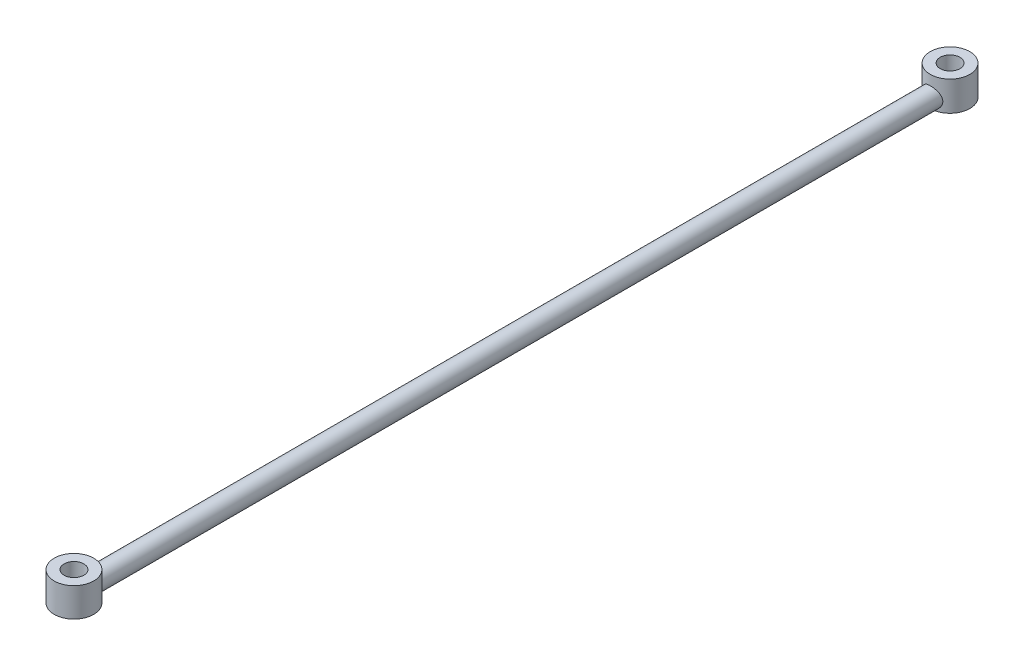
from build123d import *

# Parameters (mm, degrees)
SKETCH_1_R        = 3
SKETCH_1_R_2      = 1.5
EXTRUDE_1_DEPTH   = 3
EXTRUDE_1_2_DEPTH = 3
SKETCH_2_R        = 1.5
EXTRUDE_2_DEPTH   = 129.8
SKETCH_3_R        = 3
SKETCH_3_R_2      = 1.5
EXTRUDE_3_DEPTH   = 1.5
SKETCH_4_R        = 3
SKETCH_4_R_2      = 1.5
EXTRUDE_4_DEPTH   = 1.4


with BuildPart() as part:
    # 草图1 → 凸台-拉伸1 (new body)
    with BuildSketch(Plane(origin=(0, 0, 0), x_dir=(1, 0, 0), z_dir=(0, 1, 0))):
        Circle(SKETCH_1_R)
        Circle(SKETCH_1_R_2, mode=Mode.SUBTRACT)
    extrude(amount=EXTRUDE_1_DEPTH)



with BuildPart() as body_2:
    # 草图1 → Extrude 1 2 (new body)
    with BuildSketch(Plane(origin=(0, 0, 0), x_dir=(1, 0, 0), z_dir=(0, 1, 0))):
        with Locations((0, -133)):
            Circle(SKETCH_1_R)
        with Locations((0, -133)):
            Circle(SKETCH_1_R_2, mode=Mode.SUBTRACT)
    extrude(amount=EXTRUDE_1_2_DEPTH)


with BuildPart() as part_1:
    add(part.part)

    add(body_2.part)  # 凸台-拉伸2 merges body 2
    # 草图2 → 凸台-拉伸2 (add)
    with BuildSketch(Plane.XY.offset(1.6)):
        with Locations((0, 1.5)):
            Circle(SKETCH_2_R)
    extrude(amount=EXTRUDE_2_DEPTH)

    # 草图3 → 凸台-拉伸3 (add)
    with BuildSketch(Plane(origin=(0, 3, 0), x_dir=(1, 0, 0), z_dir=(0, 1, 0))):
        Circle(SKETCH_3_R)
        Circle(SKETCH_3_R_2, mode=Mode.SUBTRACT)
    extrude(amount=EXTRUDE_3_DEPTH)

    # 草图4 → 凸台-拉伸4 (add)
    with BuildSketch(Plane(origin=(0, 3, 0), x_dir=(1, 0, 0), z_dir=(0, 1, 0))):
        with Locations((0, -133)):
            Circle(SKETCH_4_R)
        with Locations((0, -133)):
            Circle(SKETCH_4_R_2, mode=Mode.SUBTRACT)
    extrude(amount=EXTRUDE_4_DEPTH)


solid = part_1.part
